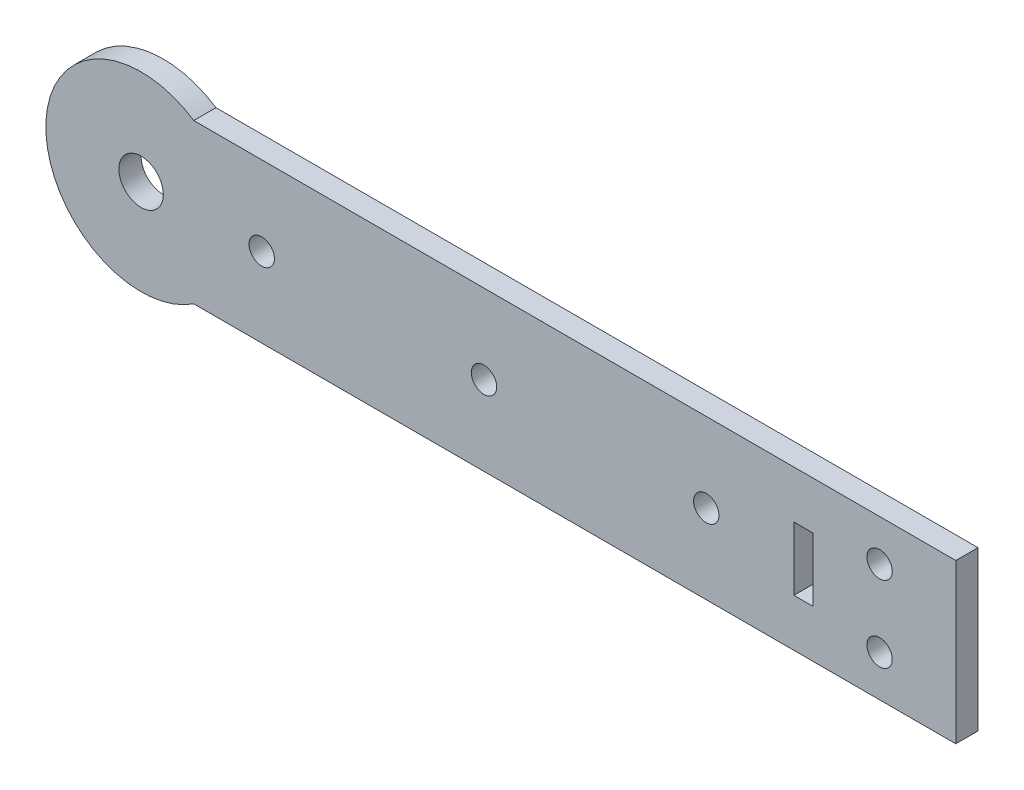
from build123d import *

# Parameters (mm, degrees)
CROQUIS1_R              = 3.5
CROQUIS1_R_2            = 2
CROQUIS1_W              = 3
CROQUIS1_H              = 10
SALIENTE_EXTRUIR2_DEPTH = 3.5


with BuildPart() as part:
    # Croquis1 → Saliente-Extruir2 (new body)
    with BuildSketch(Plane.XY):
        with BuildLine():
            Line((36.805064583, 12.5), (36.805064583, -12.5))
            Line((36.805064583, -12.5), (-83.194935417, -12.5))
            ThreePointArc((-83.194935417, -12.5), (-106.486497393, 0), (-83.194935417, 12.5))
            Line((-83.194935417, 12.5), (36.805064583, 12.5))
        make_face()
        with Locations((-91.486497393, 0)):
            Circle(CROQUIS1_R, mode=Mode.SUBTRACT)
        with Locations((-72.486497393, 0)):
            Circle(CROQUIS1_R_2, mode=Mode.SUBTRACT)
        with Locations((24.805064583, 6)):
            Circle(CROQUIS1_R_2, mode=Mode.SUBTRACT)
        with Locations((24.805064583, -6)):
            Circle(CROQUIS1_R_2, mode=Mode.SUBTRACT)
        with Locations((-37.486497393, 0)):
            Circle(CROQUIS1_R_2, mode=Mode.SUBTRACT)
        with Locations((-2.486497393, 0)):
            Circle(CROQUIS1_R_2, mode=Mode.SUBTRACT)
        with Locations((12.805064583, 0)):
            Rectangle(CROQUIS1_W, CROQUIS1_H, mode=Mode.SUBTRACT)
    extrude(amount=SALIENTE_EXTRUIR2_DEPTH)


solid = part.part
